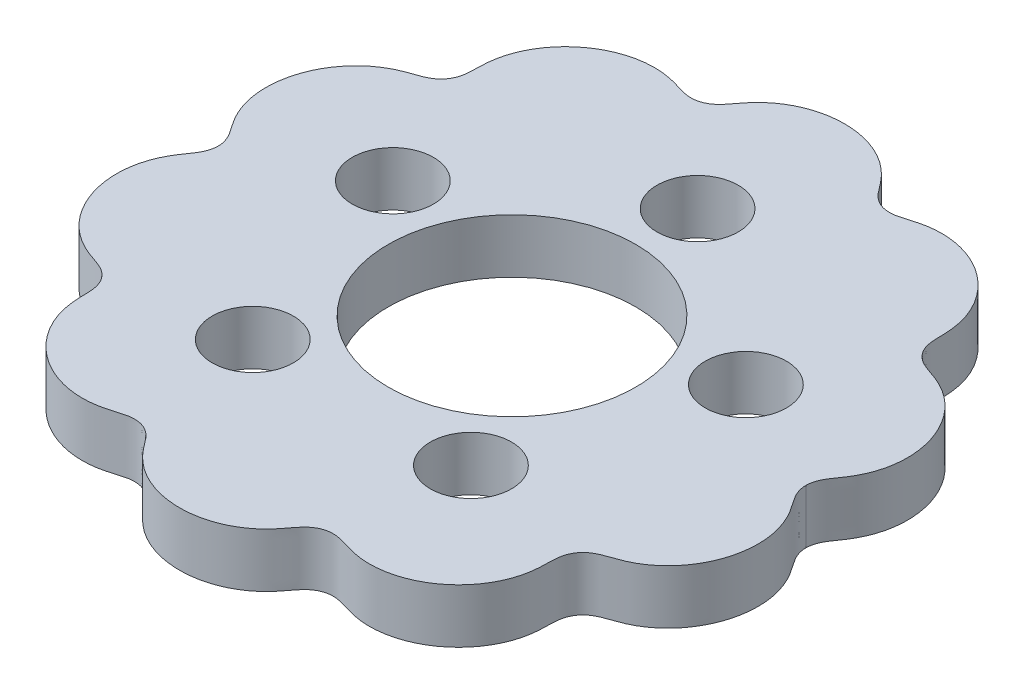
from build123d import *

# Parameters (mm, degrees)
BOSS_EXTRUDE2_DEPTH = 7
SKETCH4_R           = 16
SKETCH4_R_2         = 5.25
CUT_EXTRUDE2_DEPTH  = 7


with BuildPart() as part:
    # Sketch3 → Boss-Extrude2 (new body)
    with BuildSketch(Plane(origin=(0, 0, 0), x_dir=(1, 0, 0), z_dir=(0, 1, 0))):
        with BuildLine():
            add(Edge.make_bspline(
                [(37.999995031, 0), (37.999995035, -0.002503026), (38.000245422, -0.259072005), (38.041115325, -0.664385307), (38.184298124, -1.204218531), (38.497758519, -1.863828796), (38.845957573, -2.414590918), (39.240400102, -2.966483313), (39.642816446, -3.547136277), (40.02389545, -4.158414144), (40.371910303, -4.80492538), (40.758059592, -5.660112215), (41.249176718, -7.103950541), (41.528273903, -8.806319447), (41.497015744, -10.720900092), (41.068079826, -12.969516283), (40.260999447, -15.12021462), (39.010262728, -17.06059134), (37.503860643, -18.53568914), (36.253262216, -19.408364388), (35.435787578, -19.868863267), (34.772629468, -20.183878771), (34.103872331, -20.451363935), (33.436420645, -20.682675573), (32.793274475, -20.898288143), (32.189731784, -21.144227966), (31.55293101, -21.501852707), (30.931198626, -22.024520791), (30.459365154, -22.6931259), (30.174084853, -23.453375444), (30.045833171, -24.172212681), (30.00702788, -24.822621233), (30.002258683, -25.50097001), (29.985140425, -26.207316697), (29.932024331, -26.925746124), (29.83110415, -27.653044788), (29.637695224, -28.57128033), (29.295386908, -29.662699098), (28.748070102, -30.881436214), (27.736977534, -32.499766602), (26.451094695, -33.924087149), (24.938286022, -35.110033408), (22.908489194, -36.201739825), (21.071824436, -36.809041131), (19.345571164, -37.049085902), (17.805690706, -37.003511369), (16.874972648, -36.884814174), (16.166218504, -36.744485184), (15.489988894, -36.567949913), (14.844244119, -36.370127843), (14.216429653, -36.174272274), (13.593250528, -36.023031126), (12.867579801, -35.940520402), (12.052761517, -36.004141799), (11.280867307, -36.274248759), (10.611243958, -36.722804045), (10.095417658, -37.221701701), (9.690229479, -37.714349755), (9.296101288, -38.247922731), (8.877819773, -38.796828934), (8.423928891, -39.33741011), (7.926411033, -39.860225601), (7.243922247, -40.485424093), (6.040451793, -41.393640682), (4.194374577, -42.361093034), (1.614290804, -43.052373169), (-1.060071777, -43.072591446), (-3.301549718, -42.606476502), (-5.073108074, -41.897199704), (-6.234498632, -41.236737822), (-7.15530684, -40.558101052), (-7.853702835, -39.931284399), (-8.364652184, -39.403882059), (-8.831595833, -38.855222204), (-9.26180822, -38.294622796), (-9.664122177, -37.74838432), (-10.075380625, -37.243085064), (-10.597558744, -36.732806208), (-11.272754404, -36.277267619), (-12.049862358, -36.004367776), (-12.867576627, -35.940520847), (-13.593252632, -36.023030835), (-14.216428061, -36.174272494), (-14.844245161, -36.3701277), (-15.489988295, -36.567949996), (-16.166218833, -36.744485138), (-16.874972499, -36.884814195), (-17.80569078, -37.003511359), (-19.345571106, -37.04908591), (-21.071824473, -36.809041126), (-22.908489176, -36.201739828), (-24.938286033, -35.110033406), (-26.451094687, -33.92408715), (-27.736977538, -32.499766601), (-28.748070099, -30.881436215), (-29.295386909, -29.662699098), (-29.637695224, -28.57128033), (-29.831104148, -27.653044788), (-29.932024337, -26.925746125), (-29.985140414, -26.207316696), (-30.002258702, -25.500970013), (-30.00702785, -24.822621229), (-30.045833208, -24.172212686), (-30.174084799, -23.453375436), (-30.459365251, -22.693125914), (-30.931198474, -22.024520769), (-31.552931219, -21.501852737), (-32.189731427, -21.144227914), (-32.793275261, -20.898288257), (-33.436419083, -20.682675347), (-34.103874933, -20.451364313), (-34.772625281, -20.183878164), (-35.435793704, -19.868864155), (-36.253252735, -19.408363013), (-37.503878269, -18.535691694), (-39.010231684, -17.060586844), (-40.46951771, -14.796806618), (-41.427177517, -11.873078883), (-41.590232687, -9.184615055), (-41.249209599, -7.10395472), (-40.75804268, -5.660110565), (-40.371920503, -4.804925177), (-40.023889919, -4.158417099), (-39.642817404, -3.547129543), (-39.240403781, -2.966495762), (-38.845948976, -2.414571328), (-38.497770149, -1.863852962), (-38.184280718, -1.204183445), (-38.04113114, -0.664417555), (-38.00024784, -0.259079883), (-37.999991289, -0.002501268), (-37.999991223, 0)],
                knots=[0.119150989, 0.119150989, 0.119150989, 0.119150989, 0.119150989, 0.119204897, 0.124676716, 0.127881111, 0.131085507, 0.134889044, 0.138692582, 0.142496119, 0.146299657, 0.15039762, 0.154495582, 0.162691508, 0.179082712, 0.187278452, 0.195474192, 0.211864639, 0.228254639, 0.236449991, 0.240547667, 0.244645343, 0.248448621, 0.252251899, 0.256055177, 0.259858455, 0.263062748, 0.26626704, 0.27173875, 0.277210549, 0.280414861, 0.283619173, 0.287423012, 0.291226852, 0.295030692, 0.298834532, 0.302932646, 0.30703076, 0.315226987, 0.323422969, 0.331618951, 0.348011096, 0.356289605, 0.364568115, 0.381124408, 0.389403103, 0.39354245, 0.397681798, 0.401318219, 0.40495464, 0.408591061, 0.412227482, 0.415486356, 0.41874523, 0.424272532, 0.429682014, 0.432827837, 0.435973661, 0.439689093, 0.443404526, 0.447119958, 0.45083539, 0.454886842, 0.458938293, 0.467041196, 0.483246374, 0.499451992, 0.515844819, 0.524041184, 0.532237549, 0.540434034, 0.544532277, 0.54863052, 0.552434767, 0.556239014, 0.560043261, 0.563847509, 0.567051634, 0.570255759, 0.575727468, 0.58125477, 0.584513644, 0.587772518, 0.591408939, 0.59504536, 0.598681781, 0.602318202, 0.60645755, 0.610596897, 0.618875592, 0.635431885, 0.643710395, 0.651988904, 0.668381049, 0.676577031, 0.684773013, 0.69296924, 0.697067354, 0.701165468, 0.704969308, 0.708773148, 0.712576988, 0.716380827, 0.719585139, 0.722789451, 0.72826125, 0.73373296, 0.736937252, 0.740141545, 0.743944823, 0.747748101, 0.751551379, 0.755354657, 0.759452333, 0.763550009, 0.771745361, 0.788135361, 0.804525808, 0.820917288, 0.837308492, 0.845504418, 0.84960238, 0.853700343, 0.857503881, 0.861307418, 0.865110956, 0.868914493, 0.872118889, 0.875323284, 0.880795103, 0.88084897, 0.88084897, 0.88084897, 0.88084897, 0.88084897], degree=4))
            add(Edge.make_bspline(
                [(37.999995031, 0), (37.999995035, 0.002503026), (38.000245422, 0.259072005), (38.041115325, 0.664385307), (38.184298124, 1.204218531), (38.497758519, 1.863828796), (38.845957573, 2.414590918), (39.240400102, 2.966483313), (39.642816446, 3.547136277), (40.02389545, 4.158414144), (40.371910304, 4.80492538), (40.758059592, 5.660112215), (41.249176718, 7.103950541), (41.528273903, 8.806319447), (41.497015744, 10.720900092), (41.068079826, 12.969516283), (40.260999447, 15.12021462), (39.010262728, 17.06059134), (37.503860643, 18.53568914), (36.253262216, 19.408364388), (35.435787578, 19.868863267), (34.772629468, 20.183878771), (34.103872331, 20.451363935), (33.436420645, 20.682675573), (32.793274475, 20.898288143), (32.189731784, 21.144227966), (31.55293101, 21.501852707), (30.931198626, 22.024520791), (30.459365154, 22.6931259), (30.174084853, 23.453375444), (30.045833171, 24.172212681), (30.00702788, 24.822621233), (30.002258683, 25.50097001), (29.985140425, 26.207316697), (29.932024331, 26.925746124), (29.83110415, 27.653044788), (29.637695224, 28.57128033), (29.295386908, 29.662699098), (28.748070102, 30.881436214), (27.736977534, 32.499766602), (26.451094695, 33.924087149), (24.938286022, 35.110033408), (22.908489194, 36.201739825), (21.071824436, 36.809041131), (19.345571164, 37.049085902), (17.805690706, 37.003511369), (16.874972648, 36.884814174), (16.166218504, 36.744485184), (15.489988894, 36.567949913), (14.844244119, 36.370127843), (14.216429653, 36.174272274), (13.593250528, 36.023031126), (12.867579801, 35.940520402), (12.052761517, 36.004141799), (11.280867307, 36.274248759), (10.611243958, 36.722804045), (10.095417658, 37.221701701), (9.690229479, 37.714349755), (9.296101288, 38.247922731), (8.877819773, 38.796828934), (8.423928891, 39.33741011), (7.926411033, 39.860225601), (7.243922247, 40.485424093), (6.040451793, 41.393640682), (4.194374577, 42.361093034), (1.614290804, 43.052373169), (-1.060071777, 43.072591446), (-3.301549718, 42.606476502), (-5.073108073, 41.897199704), (-6.234498632, 41.236737822), (-7.15530684, 40.558101052), (-7.853702835, 39.931284399), (-8.364652184, 39.403882059), (-8.831595833, 38.855222204), (-9.26180822, 38.294622796), (-9.664122177, 37.74838432), (-10.075380625, 37.243085064), (-10.597558744, 36.732806208), (-11.272754404, 36.277267619), (-12.049862358, 36.004367776), (-12.867576627, 35.940520847), (-13.593252632, 36.023030835), (-14.216428061, 36.174272494), (-14.844245161, 36.3701277), (-15.489988295, 36.567949996), (-16.166218833, 36.744485138), (-16.874972499, 36.884814195), (-17.80569078, 37.003511359), (-19.345571106, 37.04908591), (-21.071824473, 36.809041126), (-22.908489176, 36.201739828), (-24.938286033, 35.110033406), (-26.451094687, 33.92408715), (-27.736977538, 32.499766601), (-28.748070099, 30.881436215), (-29.295386909, 29.662699098), (-29.637695224, 28.57128033), (-29.831104148, 27.653044788), (-29.932024337, 26.925746125), (-29.985140414, 26.207316696), (-30.002258702, 25.500970013), (-30.00702785, 24.822621229), (-30.045833208, 24.172212686), (-30.174084799, 23.453375436), (-30.459365251, 22.693125914), (-30.931198474, 22.024520769), (-31.552931219, 21.501852737), (-32.189731427, 21.144227914), (-32.793275261, 20.898288257), (-33.436419083, 20.682675347), (-34.103874933, 20.451364313), (-34.772625281, 20.183878164), (-35.435793704, 19.868864155), (-36.253252735, 19.408363013), (-37.503878269, 18.535691694), (-39.010231684, 17.060586844), (-40.46951771, 14.796806618), (-41.427177517, 11.873078883), (-41.590232687, 9.184615055), (-41.249209599, 7.10395472), (-40.75804268, 5.660110565), (-40.371920503, 4.804925177), (-40.023889919, 4.158417099), (-39.642817404, 3.547129543), (-39.240403781, 2.966495762), (-38.845948976, 2.414571328), (-38.497770149, 1.863852962), (-38.184280718, 1.204183445), (-38.04113114, 0.664417555), (-38.00024784, 0.259079883), (-37.999991289, 0.002501268), (-37.999991223, 0)],
                knots=[0.119150989, 0.119150989, 0.119150989, 0.119150989, 0.119150989, 0.119204897, 0.124676716, 0.127881111, 0.131085507, 0.134889044, 0.138692582, 0.142496119, 0.146299657, 0.15039762, 0.154495582, 0.162691508, 0.179082712, 0.187278452, 0.195474192, 0.211864639, 0.228254639, 0.236449991, 0.240547667, 0.244645343, 0.248448621, 0.252251899, 0.256055177, 0.259858455, 0.263062748, 0.26626704, 0.27173875, 0.277210549, 0.280414861, 0.283619173, 0.287423012, 0.291226852, 0.295030692, 0.298834532, 0.302932646, 0.30703076, 0.315226987, 0.323422969, 0.331618951, 0.348011096, 0.356289605, 0.364568115, 0.381124408, 0.389403103, 0.39354245, 0.397681798, 0.401318219, 0.40495464, 0.408591061, 0.412227482, 0.415486356, 0.41874523, 0.424272532, 0.429682014, 0.432827837, 0.435973661, 0.439689093, 0.443404526, 0.447119958, 0.45083539, 0.454886842, 0.458938293, 0.467041196, 0.483246374, 0.499451992, 0.515844819, 0.524041184, 0.532237549, 0.540434034, 0.544532277, 0.54863052, 0.552434767, 0.556239014, 0.560043261, 0.563847509, 0.567051634, 0.570255759, 0.575727468, 0.58125477, 0.584513644, 0.587772518, 0.591408939, 0.59504536, 0.598681781, 0.602318202, 0.60645755, 0.610596897, 0.618875592, 0.635431885, 0.643710395, 0.651988904, 0.668381049, 0.676577031, 0.684773013, 0.69296924, 0.697067354, 0.701165468, 0.704969308, 0.708773148, 0.712576988, 0.716380827, 0.719585139, 0.722789451, 0.72826125, 0.73373296, 0.736937252, 0.740141545, 0.743944823, 0.747748101, 0.751551379, 0.755354657, 0.759452333, 0.763550009, 0.771745361, 0.788135361, 0.804525808, 0.820917288, 0.837308492, 0.845504418, 0.84960238, 0.853700343, 0.857503881, 0.861307418, 0.865110956, 0.868914493, 0.872118889, 0.875323284, 0.880795103, 0.88084897, 0.88084897, 0.88084897, 0.88084897, 0.88084897], degree=4))
        make_face()
    extrude(amount=BOSS_EXTRUDE2_DEPTH)

    # Sketch4 → Cut-Extrude2 (cut)
    with BuildSketch(Plane(origin=(0, 7, 0), x_dir=(1, 0, 0), z_dir=(0, 1, 0))):
        with Locations(Location((0, 0, 0), (0, 0, 270))):
            Circle(SKETCH4_R)
        with Locations(Location((22.825373501, 7.416355207, 0), (0, 0, 270))):
            Circle(SKETCH4_R_2)
        with Locations(Location((14.106801262, -19.416440409, 0), (0, 0, 270))):
            Circle(SKETCH4_R_2)
        with Locations(Location((-14.106890848, -19.416375321, 0), (0, 0, 270))):
            Circle(SKETCH4_R_2)
        with Locations(Location((-22.825339281, 7.416460523, 0), (0, 0, 270))):
            Circle(SKETCH4_R_2)
        with Locations(Location((5.5368e-05, 24, 0), (0, 0, 270))):
            Circle(SKETCH4_R_2)
    extrude(amount=-CUT_EXTRUDE2_DEPTH, mode=Mode.SUBTRACT)


solid = part.part
